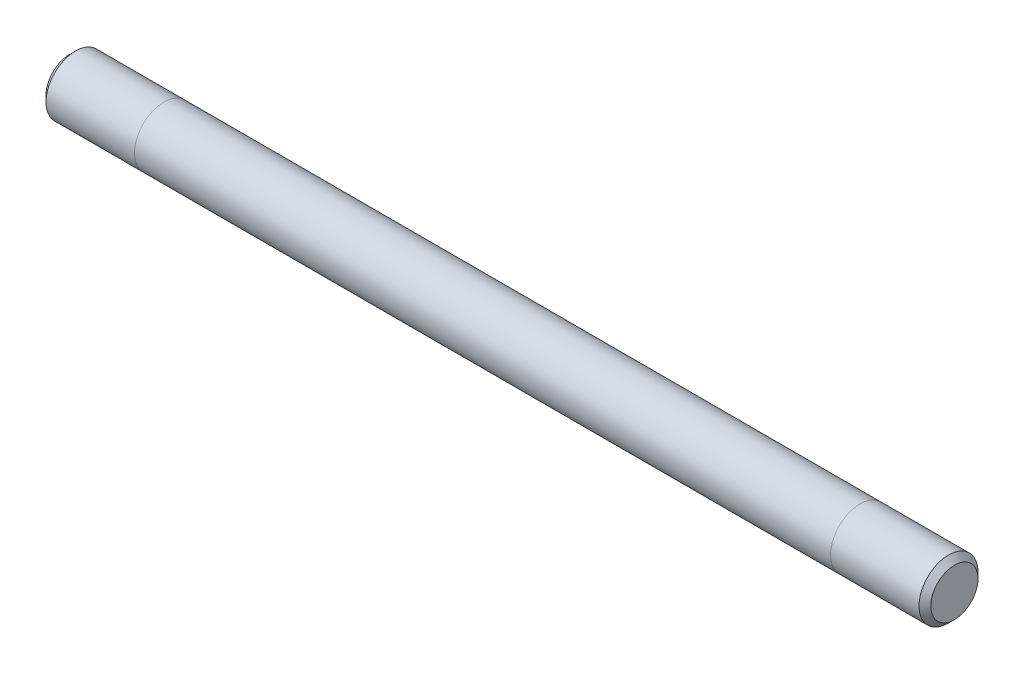
from build123d import *

# Parameters (mm, degrees)
SKIZZE1_R                       = 5
AUFSATZ_LINEAR_AUSTRAGEN1_DEPTH = 75
FASE1_SIZE                      = 1


with BuildPart() as part:
    # Skizze1 → Aufsatz-Linear austragen1 (new body, symmetric)
    with BuildSketch(Plane(origin=(0, 0, 0), x_dir=(0, 0, -1), z_dir=(1, 0, 0))):
        Circle(SKIZZE1_R)
    extrude(amount=AUFSATZ_LINEAR_AUSTRAGEN1_DEPTH, both=True)

    # Fase1
    fase1_edges = [part.edges().sort_by_distance(p)[0] for p in [
        (-75, 0, 5),
        (75, 0, 5),
    ]]
    chamfer(fase1_edges, length=FASE1_SIZE)


solid = part.part
